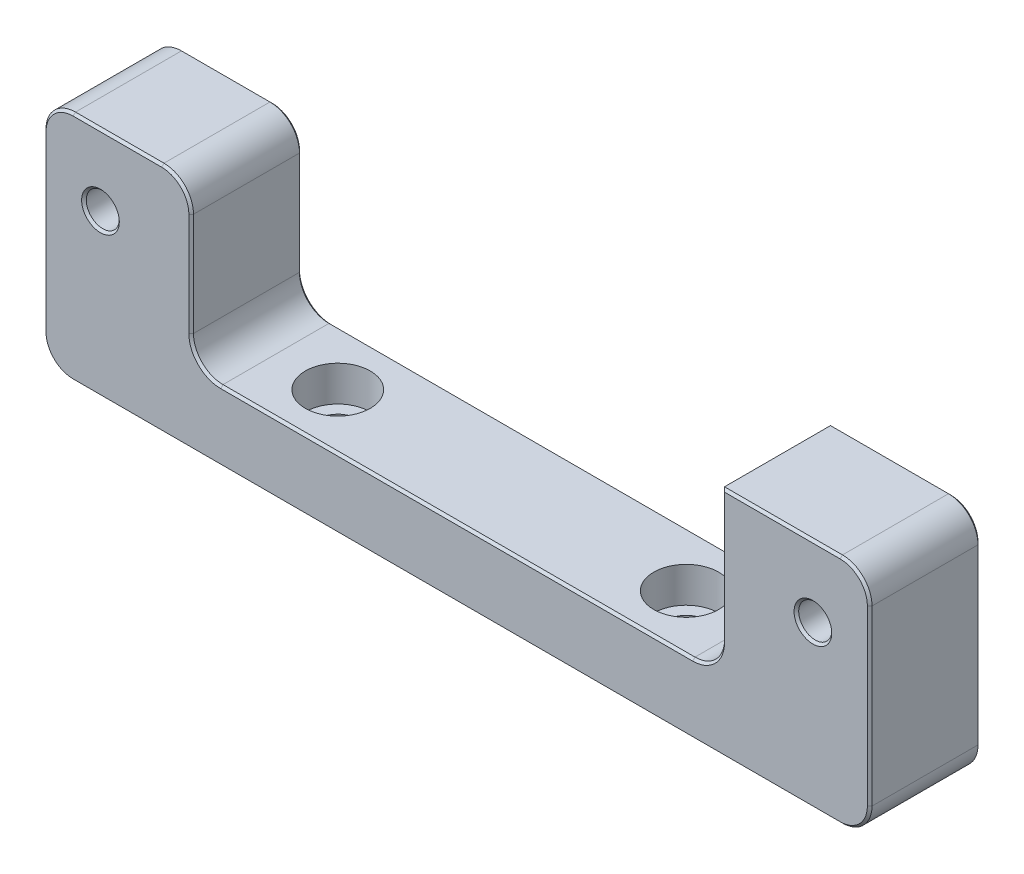
from build123d import *

# Parameters (mm, degrees)
SKETCH1_W                       = 71.12
SKETCH1_H                       = 20
EXTRUDE1_DEPTH                  = 9.525
SKETCH2_W                       = 45.72
SKETCH2_H                       = 13.97
EXTRUDE2_DEPTH                  = 10.525
HOLE1_D                         = 3.4544
HOLE1_CBORE_D                   = 5.588
HOLE1_CBORE_DEPTH               = 3.048
F_4_40_TAPPED_HOLE1_D           = 2.2606
F_4_40_TAPPED_HOLE1_DEPTH       = 12.6746
F_4_40_TAPPED_HOLE1_CBORE_D     = 2.8448
F_4_40_TAPPED_HOLE1_CBORE_DEPTH = 10.7696
F_4_40_TAPPED_HOLE1_TIP         = 0.679152758
FILLET1_R                       = 2.54
CHAMFER1_SIZE                   = 0.2


with BuildPart() as part:
    # Sketch1 → Extrude1 (new body)
    with BuildSketch(Plane.XY):
        with Locations((-35.56, 10)):
            Rectangle(SKETCH1_W, SKETCH1_H)
    extrude(amount=EXTRUDE1_DEPTH)

    # Sketch2 → Extrude2 (cut, through all)
    with BuildSketch(Plane.XY.offset(9.525)):
        with Locations((-35.56, 13.015)):
            Rectangle(SKETCH2_W, SKETCH2_H)
    extrude(amount=-EXTRUDE2_DEPTH, mode=Mode.SUBTRACT)

    # Hole1 (through all)
    with Locations(Plane(origin=(-50.56, 6.03, 4.7625), x_dir=(0, 0, 1), z_dir=(0, 1, 0))):
        with Locations((0, 0), (0, 30)):
            CounterBoreHole(HOLE1_D / 2, HOLE1_CBORE_D / 2, HOLE1_CBORE_DEPTH)

    # #4-40 Tapped Hole1
    with Locations(Plane(origin=(-66.2305, 13.9, 9.525), x_dir=(1, 0, 0), z_dir=(0, 0, 1))):
        with Locations((0, 0), (61.341, 0)):
            CounterBoreHole(F_4_40_TAPPED_HOLE1_D / 2, F_4_40_TAPPED_HOLE1_CBORE_D / 2, F_4_40_TAPPED_HOLE1_CBORE_DEPTH, depth=F_4_40_TAPPED_HOLE1_DEPTH)
            with Locations((0, 0, -(F_4_40_TAPPED_HOLE1_DEPTH + F_4_40_TAPPED_HOLE1_TIP / 2))):  # 118° drill point
                Cone(0, F_4_40_TAPPED_HOLE1_D / 2, F_4_40_TAPPED_HOLE1_TIP, mode=Mode.SUBTRACT)

    # Fillet1
    fillet1_edges = [part.edges().sort_by_distance(p)[0] for p in [
        (-58.42, 6.03, 4.7625),
        (-58.42, 20, 4.7625),
        (-12.7, 6.03, 4.7625),
        (0, 0, 4.7625),
        (-71.12, 0, 4.7625),
        (-71.12, 20, 4.7625),
        (0, 20, 4.7625),
    ]]
    fillet(fillet1_edges, radius=FILLET1_R)

    # Chamfer1
    chamfer1_edges = [part.edges().sort_by_distance(p)[0] for p in [
        (-6.3119, 13.9, 0),
        (-6.3119, 13.9, 9.525),
        (-67.6529, 13.9, 0),
        (-67.6529, 13.9, 9.525),
        (-35.56, 0, 0),
        (-35.56, 0, 9.525),
        (-64.77, 20, 0),
        (-58.42, 13.015, 0),
        (-35.56, 6.03, 0),
        (-12.7, 14.285, 0),
        (-7.62, 20, 0),
        (0, 10, 0),
        (-71.12, 10, 0),
        (-0.743948776, 19.256051224, 0),
        (-59.163948776, 19.256051224, 0),
        (-70.376051224, 19.256051224, 0),
        (-0.743948776, 0.743948776, 0),
        (-70.376051224, 0.743948776, 0),
        (-71.12, 10, 9.525),
        (-58.42, 13.015, 9.525),
        (-64.77, 20, 9.525),
        (0, 10, 9.525),
        (-7.62, 20, 9.525),
        (-12.7, 14.285, 9.525),
        (-35.56, 6.03, 9.525),
        (-0.743948776, 19.256051224, 9.525),
        (-59.163948776, 19.256051224, 9.525),
        (-70.376051224, 19.256051224, 9.525),
        (-0.743948776, 0.743948776, 9.525),
        (-70.376051224, 0.743948776, 9.525),
        (-13.443948776, 6.773948776, 9.525),
        (-13.443948776, 6.773948776, 0),
        (-57.676051224, 6.773948776, 9.525),
        (-57.676051224, 6.773948776, 0),
    ]]
    chamfer(chamfer1_edges, length=CHAMFER1_SIZE)


solid = part.part
